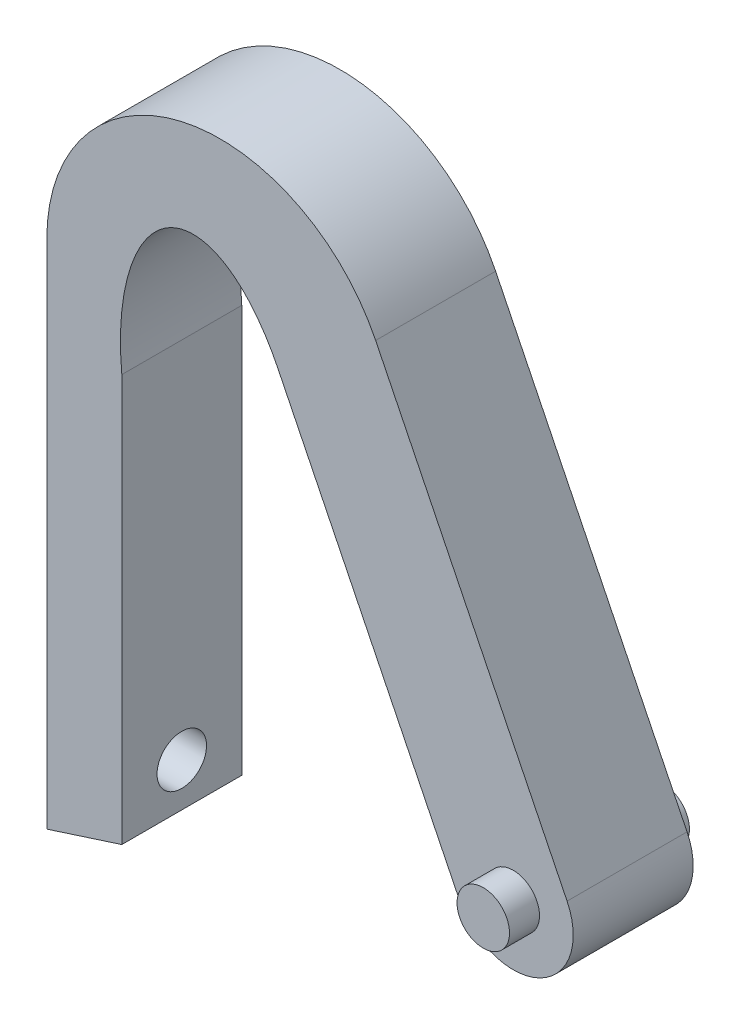
from build123d import *

# Parameters (mm, degrees)
SALIENTE_EXTRUIR1_DEPTH                        = 8
CROQUIS2_R                                     = 1.75
SALIENTE_EXTRUIR2_DEPTH                        = 2
PERFORADOR_PARA_ROSCAR_PARA_MACHO_DE_ROS_D     = 3.3
PERFORADOR_PARA_ROSCAR_PARA_MACHO_DE_ROS_DEPTH = 7
PERFORADOR_PARA_ROSCAR_PARA_MACHO_DE_ROS_TIP   = 0.991420021


with BuildPart() as part:
    # Croquis1 → Saliente-Extruir1 (new body)
    with BuildSketch(Plane.XY):
        with BuildLine():
            Line((-21.62608642, 28.286151185), (-8.859820947, 2.289392402))
            ThreePointArc((-8.859820947, 2.289392402), (-10.687098367, -3.064209864), (-16.040700634, -1.236932444))
            Line((-16.040700634, -1.236932444), (-28.162442293, 23.44734148))
            add(Edge.make_bspline(
                [(-28.162442293, 23.44734148), (-41.803068248, 51.224616152), (-38.554014675, 17.849905123)],
                knots=[2.065965679, 2.065965679, 2.065965679, 4.571411553, 4.571411553, 4.571411553], degree=2, weights=[1, 0.312737171, 1]))
            Line((-38.554014675, 17.849905123), (-38.554014675, -9.292104706))
            Line((-38.554014675, -9.292104706), (-43.554014675, -10.899488854))
            Line((-43.554014675, -10.899488854), (-43.554014675, 23.192572958))
            ThreePointArc((-43.554014675, 23.192572958), (-34.613059385, 34.4484445), (-21.62608642, 28.286151185))
        make_face()
    extrude(amount=SALIENTE_EXTRUIR1_DEPTH)

    # Croquis2 → Saliente-Extruir2 (add)
    with BuildSketch(Plane.XY.offset(8)):
        with Locations((-12.45026079, 0.526229979)):
            Circle(CROQUIS2_R)
    saliente_extruir2 = extrude(amount=SALIENTE_EXTRUIR2_DEPTH)

    # Simetría1: Saliente-Extruir2 across plane
    add(saliente_extruir2.mirror(Plane.XY.offset(4)))

    # Perforador para roscar para macho de roscar para M41
    with Locations(Plane.ZY.offset(43.554014675)):
        with Locations((4, -6.399488854)):
            Hole(PERFORADOR_PARA_ROSCAR_PARA_MACHO_DE_ROS_D / 2, depth=PERFORADOR_PARA_ROSCAR_PARA_MACHO_DE_ROS_DEPTH)
            with Locations((0, 0, -(PERFORADOR_PARA_ROSCAR_PARA_MACHO_DE_ROS_DEPTH + PERFORADOR_PARA_ROSCAR_PARA_MACHO_DE_ROS_TIP / 2))):  # 118° drill point
                Cone(0, PERFORADOR_PARA_ROSCAR_PARA_MACHO_DE_ROS_D / 2, PERFORADOR_PARA_ROSCAR_PARA_MACHO_DE_ROS_TIP, mode=Mode.SUBTRACT)


solid = part.part
